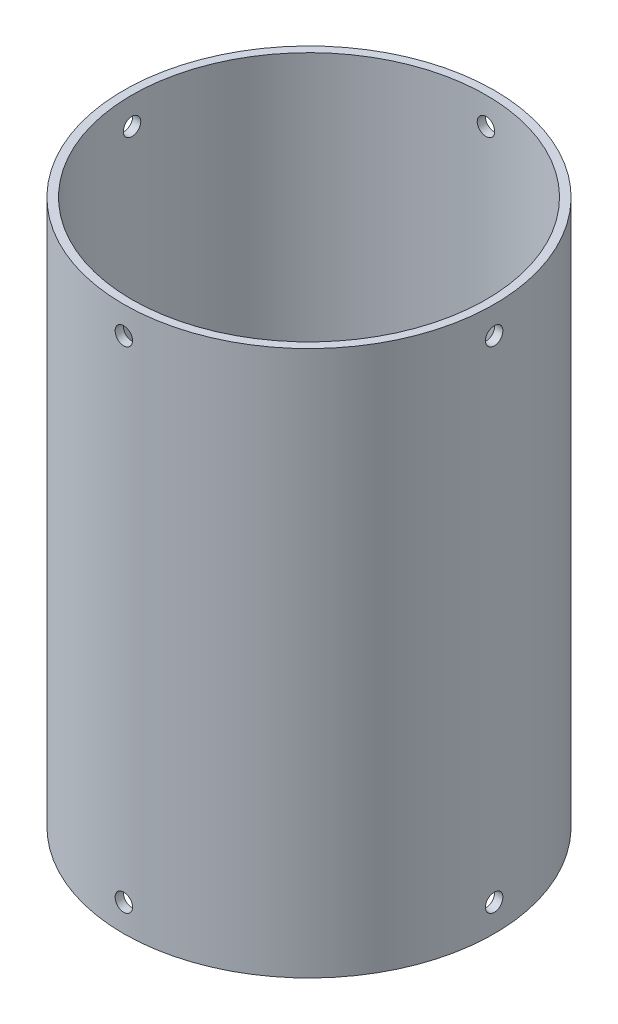
from build123d import *

# Parameters (mm, degrees)
SKETCH_1_R               = 34
SKETCH_1_R_2             = 32.5
EXTRUDE_1_DEPTH          = 100
CUT_EXTRUDE_START        = -1.539409
SKETCH_3_R               = 1.6
CUT_EXTRUDE_4_DEPTH      = 1.539409
PATTERN_CIRCULAR_1_COUNT = 4
SKETCH_5_R               = 1.6
CUT_EXTRUDE_5_DEPTH      = 1.539409
PATTERN_CIRCULAR_2_COUNT = 4


with BuildPart() as part:
    # 草图1 → 凸台-拉伸1 (new body)
    with BuildSketch(Plane(origin=(0, 0, 0), x_dir=(1, 0, 0), z_dir=(0, 1, 0))):
        Circle(SKETCH_1_R)
        Circle(SKETCH_1_R_2, mode=Mode.SUBTRACT)
    extrude(amount=EXTRUDE_1_DEPTH)

    # 草图3 → 切除-拉伸4 (cut)
    with BuildSketch(Plane.XY.offset(34).offset(CUT_EXTRUDE_START)):
        with Locations((0, 5)):
            Circle(SKETCH_3_R)
    cut_extrude_4 = extrude(amount=CUT_EXTRUDE_4_DEPTH, mode=Mode.SUBTRACT)

    # 阵列(圆周)1: 切除-拉伸4 ×4 about axis
    pattern_circular_1_axis = Axis((0, 100, 0), (0, -1, 0))
    for i in range(1, PATTERN_CIRCULAR_1_COUNT):
        add(cut_extrude_4.rotate(pattern_circular_1_axis, i * 360 / PATTERN_CIRCULAR_1_COUNT), mode=Mode.SUBTRACT)

    # 草图5 → 切除-拉伸5 (cut)
    with BuildSketch(Plane.XY.offset(34).offset(CUT_EXTRUDE_START)):
        with Locations((0, 95)):
            Circle(SKETCH_5_R)
    cut_extrude_5 = extrude(amount=CUT_EXTRUDE_5_DEPTH, mode=Mode.SUBTRACT)

    # 阵列(圆周)2: 切除-拉伸5 ×4 about axis
    pattern_circular_2_axis = Axis((0, 100, 0), (0, -1, 0))
    for i in range(1, PATTERN_CIRCULAR_2_COUNT):
        add(cut_extrude_5.rotate(pattern_circular_2_axis, i * 360 / PATTERN_CIRCULAR_2_COUNT), mode=Mode.SUBTRACT)


solid = part.part
